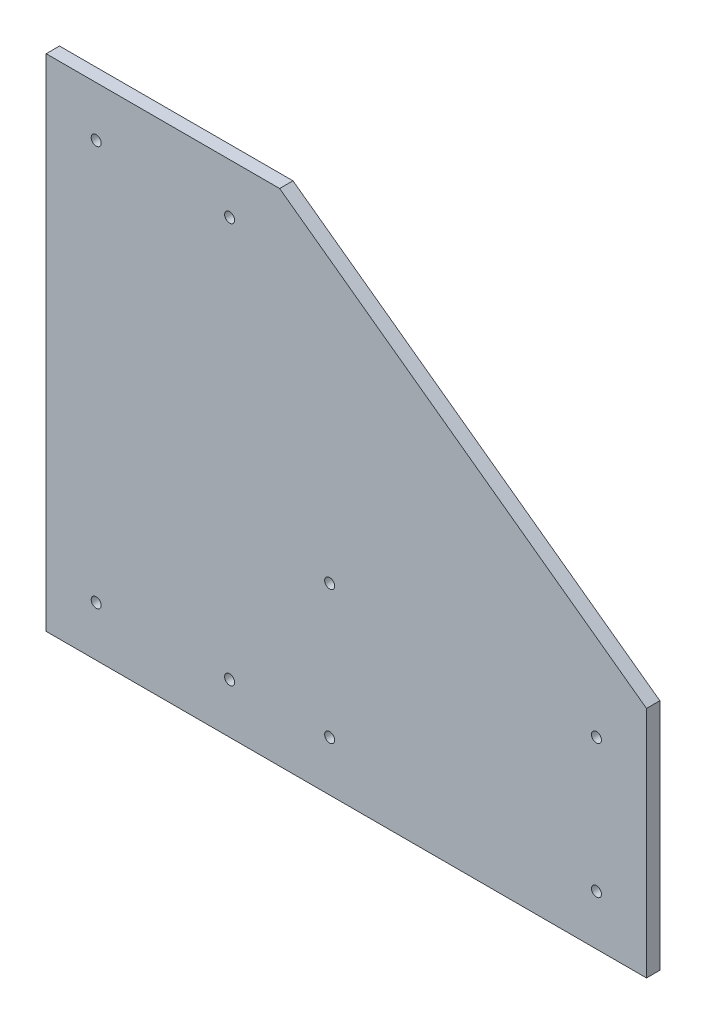
from build123d import *

# Parameters (mm, degrees)
BOSS_EXTRUDE1_DEPTH   = 5.08
F_6_CLEARANCE_HOLE1_D = 3.7973


with BuildPart() as part:
    # Sketch1 → Boss-Extrude1 (new body)
    with BuildSketch(Plane.XY):
        Polygon((0, 0), (228.6, 0), (228.6, 88.9), (88.9, 190.5), (0, 190.5), align=None)
    extrude(amount=BOSS_EXTRUDE1_DEPTH)

    # #6 Clearance Hole1 (through all)
    with Locations(Plane.XY.offset(5.08)):
        with Locations((209.55, 19.05), (19.05, 171.45), (69.85, 171.45), (69.85, 19.05), (19.05, 19.05), (107.95, 19.05), (107.95, 69.85), (209.55, 69.85)):
            Hole(F_6_CLEARANCE_HOLE1_D / 2)


solid = part.part
